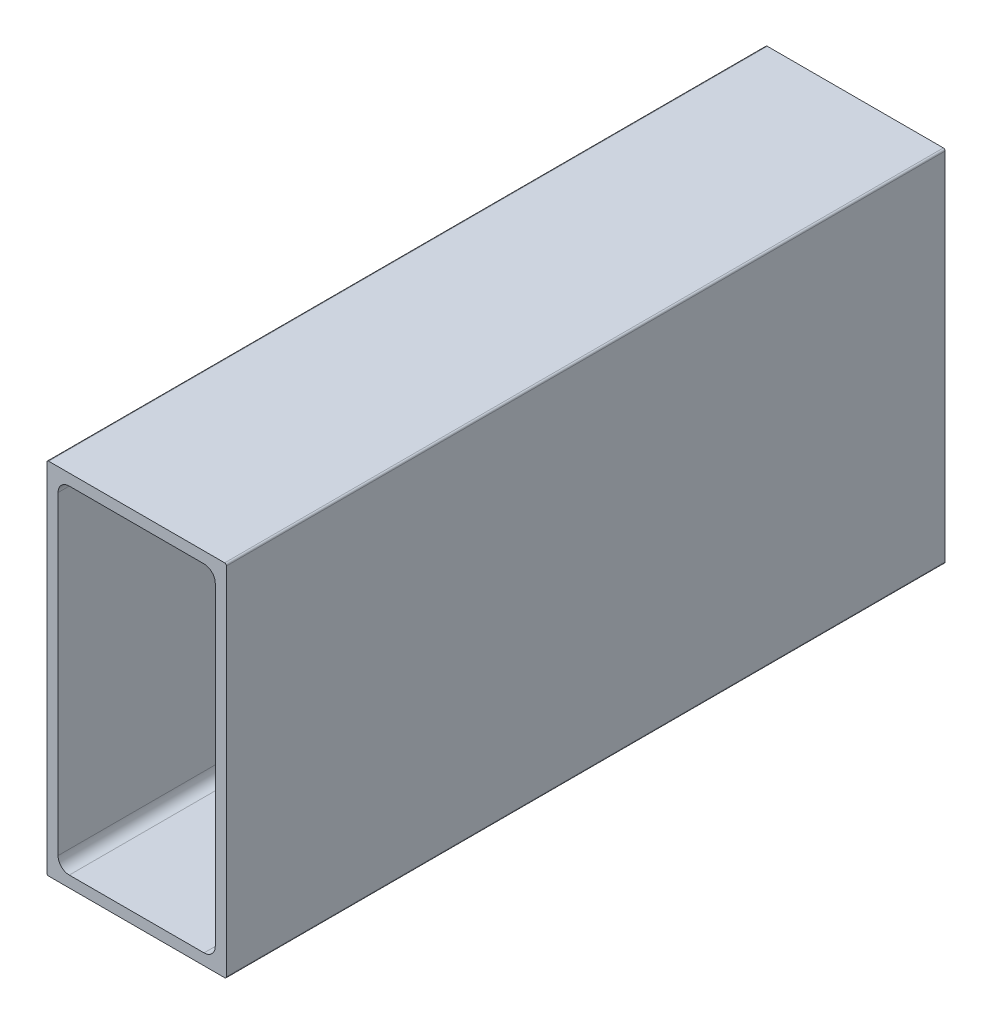
from build123d import *

# Parameters (mm, degrees)
BOSS_EXTRUDE1_DEPTH = 101.6


with BuildPart() as part:
    # Sketch1 → Boss-Extrude1 (new body)
    with BuildSketch(Plane(origin=(0, 0, 0), x_dir=(-1, 0, 0), z_dir=(0, 0, -1))):
        with BuildLine():
            Line((-12.7, 25.146), (-12.7, -25.146))
            ThreePointArc((-12.7, -25.146), (-12.625605122, -25.325605122), (-12.446, -25.4))
            Line((-12.446, -25.4), (12.446, -25.4))
            ThreePointArc((12.446, -25.4), (12.625605122, -25.325605122), (12.7, -25.146))
            Line((12.7, -25.146), (12.7, 25.146))
            ThreePointArc((12.7, 25.146), (12.625605122, 25.325605122), (12.446, 25.4))
            Line((12.446, 25.4), (-12.446, 25.4))
            ThreePointArc((-12.446, 25.4), (-12.625605122, 25.325605122), (-12.7, 25.146))
        make_face()
        with BuildLine():
            Line((-11.1125, -22.225), (-11.1125, 22.225))
            ThreePointArc((-11.1125, 22.225), (-10.647532015, 23.347532015), (-9.525, 23.8125))
            Line((-9.525, 23.8125), (9.525, 23.8125))
            ThreePointArc((9.525, 23.8125), (10.647532015, 23.347532015), (11.1125, 22.225))
            Line((11.1125, 22.225), (11.1125, -22.225))
            ThreePointArc((11.1125, -22.225), (10.647532015, -23.347532015), (9.525, -23.8125))
            Line((9.525, -23.8125), (-9.525, -23.8125))
            ThreePointArc((-9.525, -23.8125), (-10.647532015, -23.347532015), (-11.1125, -22.225))
        make_face(mode=Mode.SUBTRACT)
    extrude(amount=-BOSS_EXTRUDE1_DEPTH)


solid = part.part
